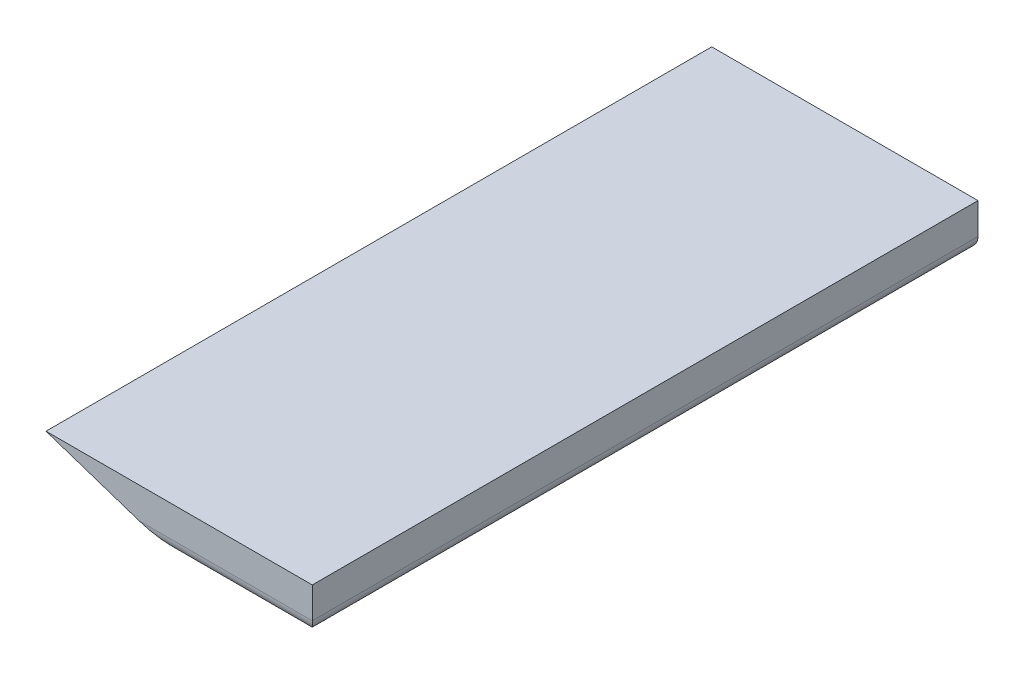
from build123d import *

# Parameters (mm, degrees)
SKETCH1_W           = 60
SKETCH1_H           = 10
BOSS_EXTRUDE1_DEPTH = 150
CUT_EXTRUDE1_DEPTH  = 50
FILLET1_R           = 3


with BuildPart() as part:
    # Sketch1 → Boss-Extrude1 (new body)
    with BuildSketch(Plane.XY):
        Rectangle(SKETCH1_W, SKETCH1_H)
    extrude(amount=BOSS_EXTRUDE1_DEPTH)

    # Sketch2 → Cut-Extrude1 (cut)
    with BuildSketch(Plane.XY.offset(150)):
        Polygon((-30, 5), (-30, -5), (0, -5), align=None)
    extrude(amount=-CUT_EXTRUDE1_DEPTH, mode=Mode.SUBTRACT)

    # Fillet1
    fillet1_edges = [part.edges().sort_by_distance(p)[0] for p in [
        (15, -5, 150),
        (-30, -5, 50),
        (-15, -5, 100),
        (30, -5, 75),
    ]]
    fillet(fillet1_edges, radius=FILLET1_R)


solid = part.part
